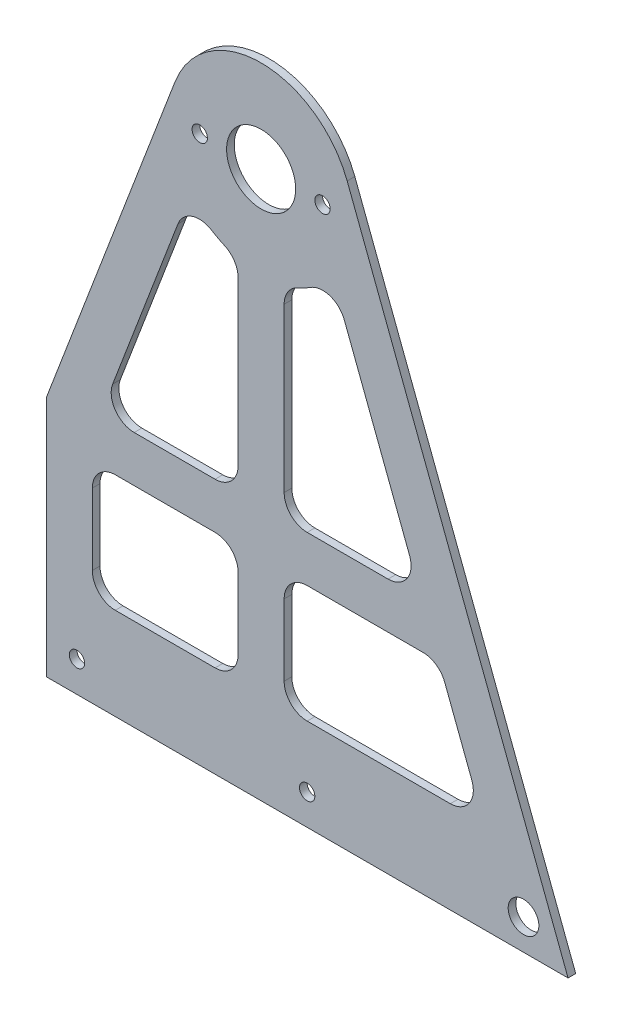
from build123d import *

# Parameters (mm, degrees)
SKETCH1_R           = 3.175
BOSS_EXTRUDE1_DEPTH = 3.175
SKETCH2_R           = 14.2875
CUT_EXTRUDE1_DEPTH  = 4.175
SKETCH4_R           = 6.35
SKETCH4_R_2         = 3.175
CUT_EXTRUDE2_DEPTH  = 4.175
SKETCH8_W           = 38.1
SKETCH8_H           = 100.0125
CUT_EXTRUDE3_DEPTH  = 4.175
SKETCH10_W          = 60.325
SKETCH10_H          = 48.559243464
CUT_EXTRUDE5_DEPTH  = 4.175
FILLET2_R           = 9.525


with BuildPart() as part:
    # Sketch1 → Boss-Extrude1 (new body)
    with BuildSketch(Plane.XY):
        with BuildLine():
            Line((-35.603982701, 119.957272705), (-127, -119.957272705))
            Line((-127, -119.957272705), (127, -119.957272705))
            Line((127, -119.957272705), (35.603982701, 119.957272705))
            ThreePointArc((35.603982701, 119.957272705), (0, 144.493850724), (-35.603982701, 119.957272705))
        make_face()
        with Locations((-25.4, 106.393850724)):
            Circle(SKETCH1_R, mode=Mode.SUBTRACT)
        with Locations((25.4, 106.393850724)):
            Circle(SKETCH1_R, mode=Mode.SUBTRACT)
    extrude(amount=BOSS_EXTRUDE1_DEPTH)

    # Sketch2 → Cut-Extrude1 (cut, through all)
    with BuildSketch(Plane.XY.offset(3.175)):
        with Locations((0, 106.393850724)):
            Circle(SKETCH2_R)
    extrude(amount=-CUT_EXTRUDE1_DEPTH, mode=Mode.SUBTRACT)

    # Sketch4 → Cut-Extrude2 (cut, through all)
    with BuildSketch(Plane.XY.offset(3.175)):
        with Locations((108.571571229, -107.257272705)):
            Circle(SKETCH4_R)
        with Locations((-76.2, -107.257272705)):
            Circle(SKETCH4_R_2)
        with Locations((19.05, -107.257272705)):
            Circle(SKETCH4_R_2)
    extrude(amount=-CUT_EXTRUDE2_DEPTH, mode=Mode.SUBTRACT)

    # Sketch8 → Cut-Extrude3 (cut, through all)
    with BuildSketch(Plane(origin=(0, 0, 0), x_dir=(-1, 0, 0), z_dir=(0, 0, -1))):
        with Locations((107.95, -69.951022705)):
            Rectangle(SKETCH8_W, SKETCH8_H)
    extrude(amount=-CUT_EXTRUDE3_DEPTH, mode=Mode.SUBTRACT)

    # Sketch10 → Cut-Extrude5 (cut, through all)
    with BuildSketch(Plane.XY.offset(3.175)):
        with BuildLine():
            Line((-9.525, 69.503684351), (-9.525, -14.248029241))
            Line((-9.525, -14.248029241), (-66.344311715, -14.248029241))
            Line((-66.344311715, -14.248029241), (-29.548259348, 82.34160822))
            ThreePointArc((-29.548259348, 82.34160822), (-20.56411854, 74.320075944), (-9.525, 69.503684351))
        make_face()
        with Locations((-39.6875, -57.577650973)):
            Rectangle(SKETCH10_W, SKETCH10_H)
        Polygon((9.525, -33.298029241), (9.525, -81.857272705), (92.100213987, -81.857272705), (73.601454572, -33.298029241), align=None)
        with BuildLine():
            Line((9.525, -14.248029241), (66.344311715, -14.248029241))
            Line((66.344311715, -14.248029241), (29.548259348, 82.34160822))
            ThreePointArc((29.548259348, 82.34160822), (20.56411854, 74.320075944), (9.525, 69.503684351))
            Line((9.525, 69.503684351), (9.525, -14.248029241))
        make_face()
    extrude(amount=-CUT_EXTRUDE5_DEPTH, mode=Mode.SUBTRACT)

    # Fillet2
    fillet2_edges = [part.edges().sort_by_distance(p)[0] for p in [
        (-29.548259348, 82.34160822, 1.5875),
        (-9.525, 69.503684351, 1.5875),
        (-9.525, -14.248029241, 1.5875),
        (-66.344311715, -14.248029241, 1.5875),
        (-69.85, -33.298029241, 1.5875),
        (-9.525, -33.298029241, 1.5875),
        (-9.525, -81.857272705, 1.5875),
        (-69.85, -81.857272705, 1.5875),
        (9.525, -33.298029241, 1.5875),
        (73.601454572, -33.298029241, 1.5875),
        (92.100213987, -81.857272705, 1.5875),
        (9.525, -81.857272705, 1.5875),
        (9.525, -14.248029241, 1.5875),
        (9.525, 69.503684351, 1.5875),
        (29.548259348, 82.34160822, 1.5875),
        (66.344311715, -14.248029241, 1.5875),
    ]]
    fillet(fillet2_edges, radius=FILLET2_R)


solid = part.part
